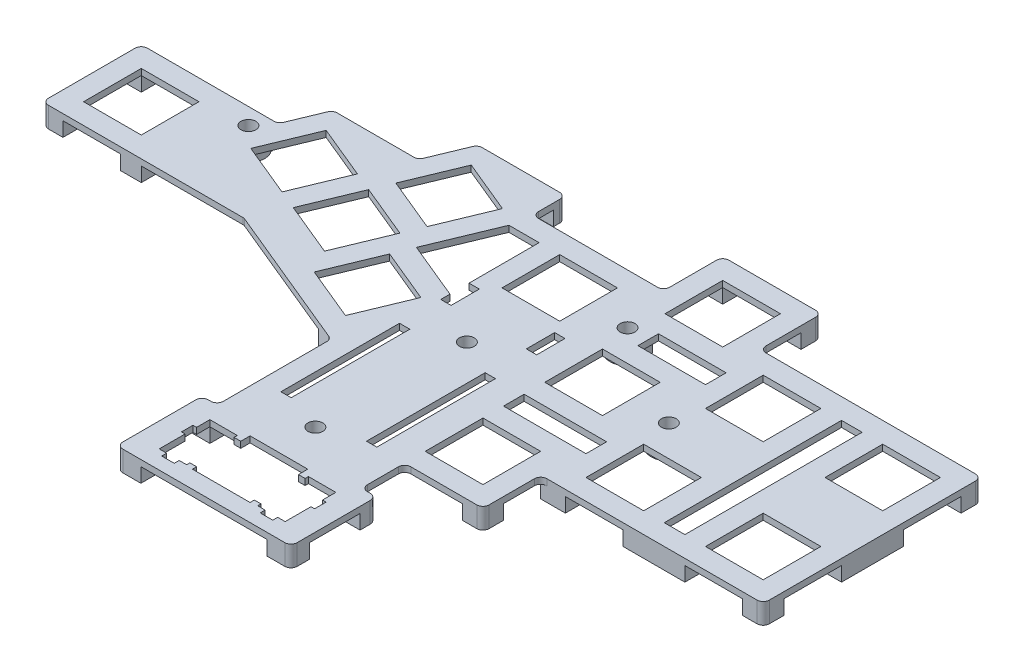
from build123d import *

# Parameters (mm, degrees)
SKETCH2_W                      = 14
SKETCH2_H                      = 14.000000000000007
SKETCH2_H_2                    = 13.999999999999986
SKETCH2_H_3                    = 14
KEY_PLATE_DEPTH                = 1.5
SKETCH3_R                      = 4.250000000000007
SKETCH3_R_2                    = 4.250000482672308
SKETCH3_R_3                    = 4.25936382153644
SKETCH3_R_4                    = 4.259363821536381
SKETCH3_W                      = 5.000000000000014
SKETCH3_H                      = 5
SKETCH3_W_2                    = 5
SKETCH3_H_2                    = 5.0000000000000036
SKETCH3_W_3                    = 4.999999999999787
SKETCH3_H_3                    = 4.999999999999986
SKETCH3_H_4                    = 5.000000000000014
SKETCH3_W_4                    = 4.999999999999995
SKETCH3_H_5                    = 5.000000000000028
SKETCH3_W_5                    = 6.000000000000007
SKETCH3_H_6                    = 5.000000000000007
SKETCH3_W_6                    = 5.0000000000000036
SKETCH3_W_7                    = 4.999999999999986
SKETCH3_W_8                    = 16.229925755521414
SKETCH3_H_7                    = 3.0000000000000284
SKETCH3_W_9                    = 5.874999999999995
SKETCH3_H_8                    = 3.970000000000007
FEET_DEPTH                     = 3.5
M3_CLEARANCE_HOLE1_D           = 3.6
M3_CLEARANCE_HOLE1_CSINK_D     = 3.65
M3_CLEARANCE_HOLE1_CSINK_ANGLE = 90
FILLET1_R                      = 1.5
SKETCH6_W                      = 4.999999999999993
SKETCH6_H                      = 42.99999999999998
SKETCH6_W_2                    = 16.403943223578576
SKETCH6_H_2                    = 4.999439423707344
CUT_EXTRUDE1_DEPTH             = 10


with BuildPart() as part:
    # Sketch2 → Key Plate (new body)
    with BuildSketch(Plane(origin=(0, 0, 0), x_dir=(1, 0, 0), z_dir=(0, 1, 0))):
        Polygon((90.50000000000016, 34), (90.50000000000016, 86.99999999999999), (36.68031392272404, 86.99999999999999), (36.68031392272404, 101.99943942370737), (12.680313922724041, 101.99943942370737), (12.680313922724034, 87.65587614958858), (-19.133111224190092, 87.6558761495886), (-19.133111224190095, 95.73148336507455), (-40.40831786894456, 95.73148336507455), (-44.67877093426948, 85.42169765728949), (-65.29834234983872, 85.42169765728949), (-69.19749747071562, 76.00830448267212), (-102.40394322357845, 76.00830448267213), (-102.40394322357845, 52.00830448267212), (-53.463346389355216, 52.008304482672116), (-17.499999999999996, 37.111798659879476), (-17.5, 9.500000000000002), (-21.152399999999997, 9.5), (-21.1524, -11.219999999999999), (21.1524, -11.219999999999994), (21.1524, 9.500000000000005), (17.5, 9.500000000000002), (17.5, 19.99999999999999), (36.50000000000015, 20), (36.50000000000015, 33.99999999999999), align=None)
        with Locations((-90.40394322357866, 64.00830448267212)):
            Rectangle(SKETCH2_W, SKETCH2_H, mode=Mode.SUBTRACT)
        Polygon((-67.31501721335357, 67.4873842021315), (-61.95744916024225, 80.42169765728949), (-49.023135705084265, 75.06412960417816), (-54.380703758195594, 62.12981614902017), align=None, mode=Mode.SUBTRACT)
        Polygon((-31.42323061074498, 67.7740102176234), (-44.357544065902964, 73.13157827073474), (-49.71511211901429, 60.19726481557674), (-36.78079866385631, 54.83969676246541), align=None, mode=Mode.SUBTRACT)
        Polygon((-7.524094275076436, 68.6558761495886), (6.4759057249235665, 68.6558761495886), (6.475905724923569, 82.6558761495886), (-7.524094275076436, 82.6558761495886), align=None, mode=Mode.SUBTRACT)
        with Locations((24.680313922724036, 89.99943942370734)):
            Rectangle(SKETCH2_W, SKETCH2_H_2, mode=Mode.SUBTRACT)
        Polygon((17.500000000000156, 67.99999999999999), (31.500000000000153, 67.99999999999999), (31.50000000000016, 54.00000000000001), (17.50000000000016, 54), align=None, mode=Mode.SUBTRACT)
        Polygon((17.500000000000153, 39), (31.500000000000153, 39), (31.500000000000153, 24.999999999999996), (17.500000000000153, 25), align=None, mode=Mode.SUBTRACT)
        with Locations((49.500000000000156, 46)):
            Rectangle(SKETCH2_W, SKETCH2_H, mode=Mode.SUBTRACT)
        Polygon((42.50000000000014, 82), (56.50000000000014, 82), (56.50000000000015, 68), (42.50000000000015, 68), align=None, mode=Mode.SUBTRACT)
        with Locations((78.50000000000017, 75)):
            Rectangle(SKETCH2_W, SKETCH2_H_3, mode=Mode.SUBTRACT)
        with Locations((78.50000000000014, 46)):
            Rectangle(SKETCH2_W, SKETCH2_H, mode=Mode.SUBTRACT)
        Polygon((7.000000000000003, 4.73), (8.622600000000002, 4.73), (8.622599999999998, 5.53), (15.2774, 5.529999999999997), (15.2774, 2.3), (16.152399999999997, 2.3), (16.152399999999997, -0.5), (15.277400000000002, -0.5000000000000001), (15.277400000000002, -6.77), (13.474, -6.769999999999999), (13.474, -7.97), (10.426000000000002, -7.97), (10.426000000000002, -6.769999999999998), (8.622599999999998, -6.77), (8.622600000000002, -5.97), (7.000000000000003, -5.97), (7, -7), (-7, -7), (-6.999999999999999, -5.9700000000000015), (-8.622599999999998, -5.9700000000000015), (-8.622599999999995, -6.770000000000001), (-10.425999999999998, -6.7700000000000005), (-10.425999999999998, -7.9700000000000015), (-13.473999999999997, -7.970000000000003), (-13.473999999999997, -6.770000000000002), (-15.277399999999998, -6.770000000000003), (-15.277399999999998, -0.5000000000000039), (-16.152399999999997, -0.5000000000000039), (-16.152399999999997, 2.2999999999999963), (-15.2774, 2.2999999999999963), (-15.2774, 5.529999999999993), (-8.6226, 5.529999999999995), (-8.622600000000002, 4.729999999999999), (-7.000000000000003, 4.729999999999999), (-7, 7), (6.999999999999999, 7), align=None, mode=Mode.SUBTRACT)
        Polygon((-33.64594075413475, 49.21162729897667), (-20.711627298976765, 43.85405924586534), (-15.354059245865443, 56.78837270102332), (-28.288372701023423, 62.14594075413465), align=None, mode=Mode.SUBTRACT)
        Polygon((-42.42499273245941, 77.79716990991656), (-37.067424679348086, 90.73148336507454), (-24.133111224190095, 85.37391531196322), (-29.490679277301425, 72.43960185680523), align=None, mode=Mode.SUBTRACT)
    extrude(amount=KEY_PLATE_DEPTH)

    # Sketch3 → Feet (add)
    with BuildSketch(Plane.XZ):
        with Locations(Location((-0.403943223578479, -53.000000482672064, 0), (0, 0, 90))):
            Circle(SKETCH3_R)
        with Locations(Location((-0.9039432235784794, -16.75000048267211, 0), (0, 0, 90))):
            Circle(SKETCH3_R_2)
        with Locations(Location((41.09605677642153, -60.50000048267209, 0), (0, 0, 90))):
            Circle(SKETCH3_R_3)
        with Locations(Location((16.096056776421534, -75.50000048267209, 0), (0, 0, 90))):
            Circle(SKETCH3_R_4)
        Polygon((-20.71162729897681, -43.85405924586534), (-22.62504446080229, -39.23466158330892), (-18.005646798245813, -37.32124442148343), (-16.09222963642034, -41.94064208403986), align=None)
        with Locations((88.00000000000014, -36.5)):
            Rectangle(SKETCH3_W, SKETCH3_H)
        with Locations((34.00000000000015, -22.5)):
            Rectangle(SKETCH3_W_2, SKETCH3_H_2)
        with Locations((-99.90394322357855, -54.508304482672116)):
            Rectangle(SKETCH3_W_3, SKETCH3_H_3)
        with Locations((-99.90394322357855, -73.50830448267212)):
            Rectangle(SKETCH3_W_3, SKETCH3_H_4)
        Polygon((-83.40394322357866, -57.008304482672116), (-78.40394322357866, -57.008304482672116), (-78.40394322357866, -52.00830448267212), (-83.40394322357866, -52.00830448267213), align=None)
        with Locations((15.18031392272404, -99.49943942370736)):
            Rectangle(SKETCH3_W_4, SKETCH3_H_5)
        with BuildLine():
            Line((-83.40394322357866, -71.00830448267212), (-76.20516958558575, -71.00830448267212))
            ThreePointArc((-76.20516958558575, -71.00830448267212), (-70.74635487704053, -68.43837393219596), (-69.19749747071565, -74.26968954630681))
            Line((-69.19749747071565, -74.26968954630681), (-69.19749747071565, -76.00830448267213))
            Line((-69.19749747071565, -76.00830448267213), (-83.40394322357866, -76.00830448267213))
            Line((-83.40394322357866, -76.00830448267213), (-83.40394322357866, -71.00830448267212))
        make_face()
        with Locations((39.500000000000156, -36.5)):
            Rectangle(SKETCH3_W_5, SKETCH3_H_6)
        Polygon((56.500000000000156, -39), (71.50000000000014, -39), (71.50000000000014, -33.99999999999999), (56.500000000000156, -34), align=None)
        Polygon((85.50000000000014, -53), (90.50000000000016, -53), (90.50000000000016, -68), (85.50000000000017, -68), align=None)
        with Locations((34.18031392272404, -99.49943942370736)):
            Rectangle(SKETCH3_W_6, SKETCH3_H_5)
        with Locations((88.00000000000017, -84.5)):
            Rectangle(SKETCH3_W_7, SKETCH3_H_3)
        with Locations((-27.248074101950802, -94.23148336507455)):
            Rectangle(SKETCH3_W_8, SKETCH3_H_7)
        Polygon((21.1524, 11.219999999999994), (15.2774, 11.219999999999994), (15.277400000000002, 6.77), (21.1524, 6.7700000000000005), align=None)
        Polygon((-21.1524, 11.219999999999999), (-15.2774, 11.219999999999999), (-15.277399999999998, 6.770000000000003), (-21.1524, 6.770000000000003), align=None)
        Polygon((21.1524, -9.500000000000005), (15.2774, -9.500000000000005), (15.2774, -5.529999999999997), (21.1524, -5.529999999999996), align=None)
        with Locations((-18.2149, -7.514999999999997)):
            Rectangle(SKETCH3_W_9, SKETCH3_H_8)
    extrude(amount=FEET_DEPTH)

    # M3 Clearance Hole1 (through all)
    with Locations(Plane(origin=(-0.403943224, -3.5, -53.000000483), x_dir=(0, 0, -1), z_dir=(0, -1, 0))):
        with Locations((0, 0), (7.5, 41.5), (22.5, 16.5), (-36.25, -0.5), (19, -72)):
            CounterSinkHole(M3_CLEARANCE_HOLE1_D / 2, M3_CLEARANCE_HOLE1_CSINK_D / 2, counter_sink_angle=M3_CLEARANCE_HOLE1_CSINK_ANGLE)

    # Fillet1
    fillet1_edges = [part.edges().sort_by_distance(p)[0] for p in [
        (-21.1524, -1, 11.219999999999999),
        (-21.152399999999997, -1, -9.5),
        (-17.5, 0.75, -9.500000000000002),
        (-17.499999999999996, 0.75, -37.111798659879476),
        (-53.463346389355216, 0.75, -52.008304482672116),
        (-102.40394322357845, -1, -52.00830448267212),
        (-102.40394322357845, -1, -76.00830448267213),
        (-69.19749747071562, 0.75, -76.00830448267212),
        (-65.29834234983872, 0.75, -85.42169765728949),
        (-44.67877093426948, 0.75, -85.42169765728949),
        (-40.40831786894456, 0.75, -95.73148336507455),
        (-19.133111224190095, -1, -95.73148336507455),
        (-19.133111224190092, 0.75, -87.6558761495886),
        (12.680313922724034, 0.75, -87.65587614958858),
        (12.680313922724041, -1, -101.99943942370737),
        (90.50000000000016, -1, -34),
        (36.50000000000015, 0.75, -33.99999999999999),
        (36.50000000000015, -1, -20),
        (17.5, 0.75, -19.99999999999999),
        (17.5, 0.75, -9.500000000000002),
        (21.1524, -1, -9.500000000000005),
        (21.1524, -1, 11.219999999999994),
        (36.68031392272404, -1, -101.99943942370737),
        (36.68031392272404, 0.75, -86.99999999999999),
        (90.50000000000016, -1, -86.99999999999999),
    ]]
    fillet(fillet1_edges, radius=FILLET1_R)

    # Sketch6 → Cut-Extrude1 (cut)
    with BuildSketch(Plane(origin=(0, 0, 0), x_dir=(-1, 0, 0), z_dir=(0, -1, 0))):
        Polygon((12.524094275076438, 58.78837270102333), (10.024094275076438, 58.78837270102333), (10.024094275076443, 65.6558761495886), (12.524094275076443, 65.6558761495886), (12.524094275076436, 82.6558761495886), (19.846998906844885, 82.6558761495886), (26.42114951582352, 66.78447258830933), (12.52409427507644, 61.0281238305437), align=None)
        Polygon((-10.750000000000156, 65.6558761495886), (-8.250000000000156, 65.6558761495886), (-8.250000000000156, 58.78837270102332), (-10.750000000000155, 58.78837270102332), align=None)
        with Locations((-64.00000000000014, 60.499999999999986)):
            Rectangle(SKETCH6_W, SKETCH6_H)
        Polygon((-37.500000000000156, 49), (-17.500000000000153, 49.000000000000014), (-17.500000000000153, 44), (-37.500000000000156, 44), align=None)
        with Locations((-29.298028388210852, 75.49971971185367)):
            Rectangle(SKETCH6_W_2, SKETCH6_H_2)
        Polygon((-10.750000000000151, 20), (-8.250000000000151, 20.000000000000004), (-8.250000000000155, 48.78837270102331), (-10.750000000000155, 48.78837270102331), align=None)
        Polygon((12.524094275076443, 20), (10.024094275076441, 20), (10.024094275076438, 48.78837270102332), (12.524094275076438, 48.78837270102332), align=None)
    extrude(amount=-CUT_EXTRUDE1_DEPTH, mode=Mode.SUBTRACT)


solid = part.part
